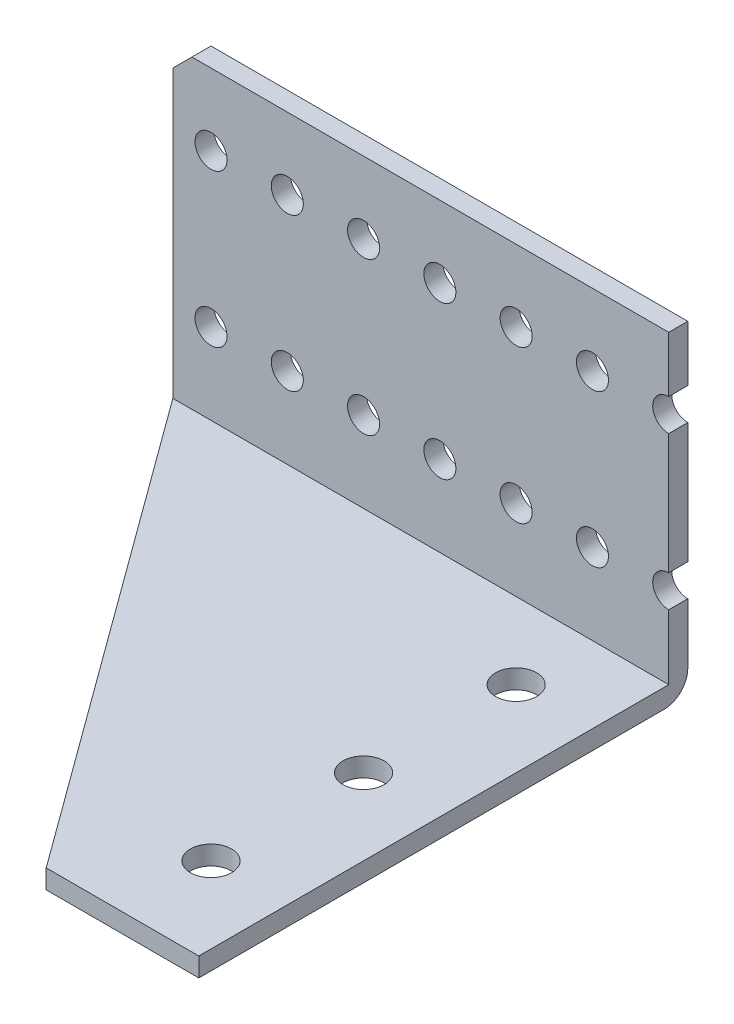
from build123d import *

# Parameters (mm, degrees)
BOSS_EXTRUDE1_START    = -34.925
SKETCH1_W              = 82.55
SKETCH1_H              = 81.407
BOSS_EXTRUDE1_DEPTH    = 3.175
SKETCH3_W              = 82.55
SKETCH3_H              = 3.175
BOSS_EXTRUDE2_DEPTH    = 50.8
F_10_CLEARANCE_HOLE2_D = 5.334
CHAMFER1_SIZE          = 3.175
FILLET2_R              = 3.937
SKETCH9_R              = 3.429
CUT_EXTRUDE2_DEPTH     = 54.975


with BuildPart() as part:
    # Sketch1 → Boss-Extrude1 (new body)
    with BuildSketch(Plane(origin=(0, 0, 0), x_dir=(1, 0, 0), z_dir=(0, 1, 0)).offset(BOSS_EXTRUDE1_START)):
        Rectangle(SKETCH1_W, SKETCH1_H)
    extrude(amount=BOSS_EXTRUDE1_DEPTH)

    # Sketch3 → Boss-Extrude2 (add)
    with BuildSketch(Plane(origin=(0, -31.75, 0), x_dir=(1, 0, 0), z_dir=(0, 1, 0))):
        with Locations((0, 39.116)):
            Rectangle(SKETCH3_W, SKETCH3_H)
    extrude(amount=BOSS_EXTRUDE2_DEPTH)

    # #10 Clearance Hole2 (through all)
    with Locations(Plane(origin=(0, 0, -40.7035), x_dir=(-1, 0, 0), z_dir=(0, 0, -1))):
        with Locations((22.225, 7.112), (9.525, 7.112), (-3.175, 7.112), (-15.875, 7.112), (-28.575, 7.112), (22.225, -18.288), (9.525, -18.288), (-3.175, -18.288), (-15.875, -18.288), (-28.575, -18.288), (34.925, 7.112), (34.925, -18.288), (-41.275, 7.112), (-41.275, -18.288)):
            Hole(F_10_CLEARANCE_HOLE2_D / 2)

    # Chamfer1
    chamfer1_edges = [part.edges().sort_by_distance(p)[0] for p in [
        (-41.275, 19.05, -39.116),
    ]]
    chamfer(chamfer1_edges, length=CHAMFER1_SIZE)

    # Fillet2
    fillet2_edges = [part.edges().sort_by_distance(p)[0] for p in [
        (0, -34.925, -40.7035),
    ]]
    fillet(fillet2_edges, radius=FILLET2_R)

    # Sketch9 → Cut-Extrude2 (cut, through all)
    with BuildSketch(Plane.XZ.offset(34.925)):
        with Locations((28.575, -24.8285)):
            Circle(SKETCH9_R)
        with Locations((28.575, 0.5715)):
            Circle(SKETCH9_R)
        with Locations((28.575, 25.9715)):
            Circle(SKETCH9_R)
        Polygon((-41.275, -37.5285), (-41.275, 40.7035), (15.875, 40.7035), align=None)
    extrude(amount=-CUT_EXTRUDE2_DEPTH, mode=Mode.SUBTRACT)


solid = part.part
